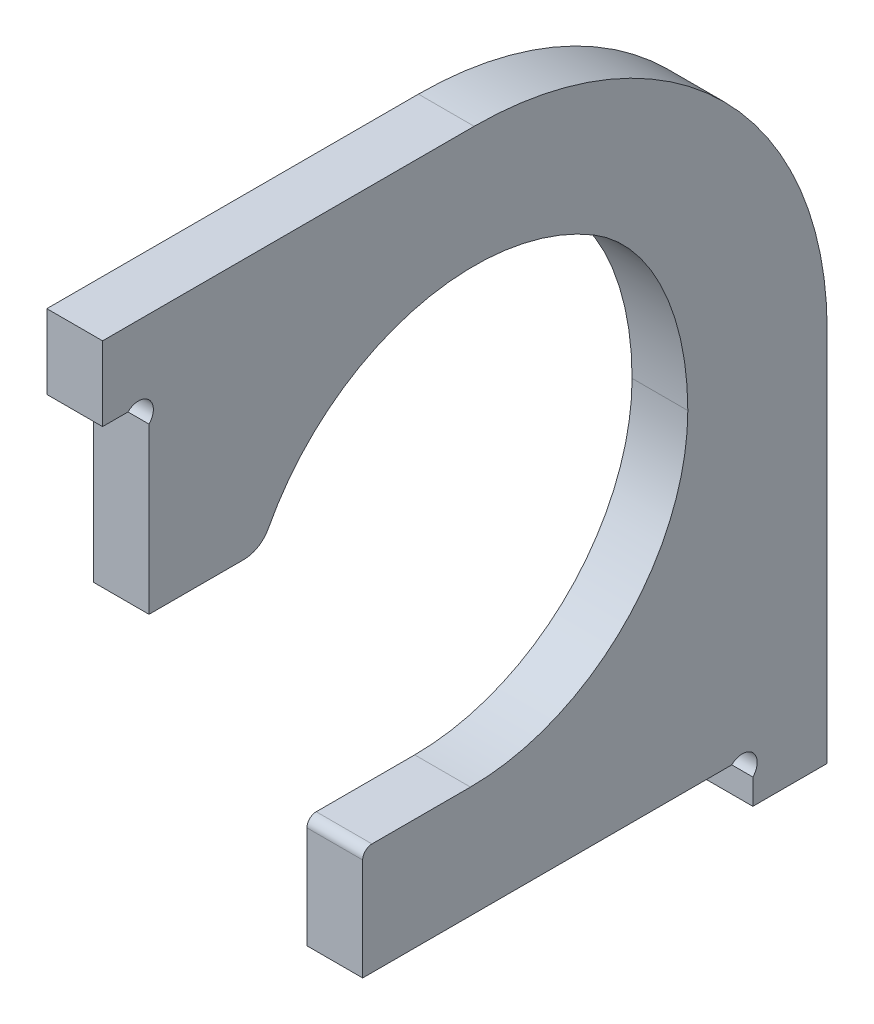
from build123d import *

# Parameters (mm, degrees)
BOSS_EXTRU_1_DEPTH = 6


with BuildPart() as part:
    # Esquisse1 → Boss.-Extru.1 (new body)
    with BuildSketch(Plane(origin=(0, 0, 0), x_dir=(0, 0, -1), z_dir=(1, 0, 0))):
        with BuildLine():
            Line((40.6, 18), (30, 18))
            ThreePointArc((30, 18), (29.292893219, 17.707106781), (29, 17))
            Line((29, 17), (29, 6))
            Line((29, 6), (68.7372583, 6))
            ThreePointArc((68.7372583, 6), (71, 6), (71, 3.7372583))
            Line((71, 3.7372583), (71, 1))
            Line((71, 1), (79, 1))
            Line((79, 1), (79, 41.4))
            ThreePointArc((79, 41.4), (67.870057685, 68.270057685), (41, 79.4))
            Line((41, 79.4), (1, 79.4))
            Line((1, 79.4), (1, 71.4))
            Line((1, 71.4), (3.7372583, 71.4))
            ThreePointArc((3.7372583, 71.4), (6, 71.4), (6, 69.1372583))
            Line((6, 69.1372583), (6, 51.4))
            Line((6, 51.4), (16.200806465, 51.4))
            ThreePointArc((16.200806465, 51.4), (17.753453973, 51.833039596), (18.857862915, 53.007142857))
            ThreePointArc((18.857862915, 53.007142857), (34.226480954, 65.464900576), (53.836840786, 62.852634305))
            add(Edge.make_bspline(
                [(64, 41.4), (64, 56.771196713), (53.836840786, 62.852634305)],
                knots=[1.570796327, 1.570796327, 1.570796327, 2.734829654, 2.734829654, 2.734829654], degree=2, weights=[1, 0.83535577, 1]))
            ThreePointArc((64, 41.4), (57.14629868, 24.85370132), (40.6, 18))
        make_face()
    extrude(amount=BOSS_EXTRU_1_DEPTH)


solid = part.part
